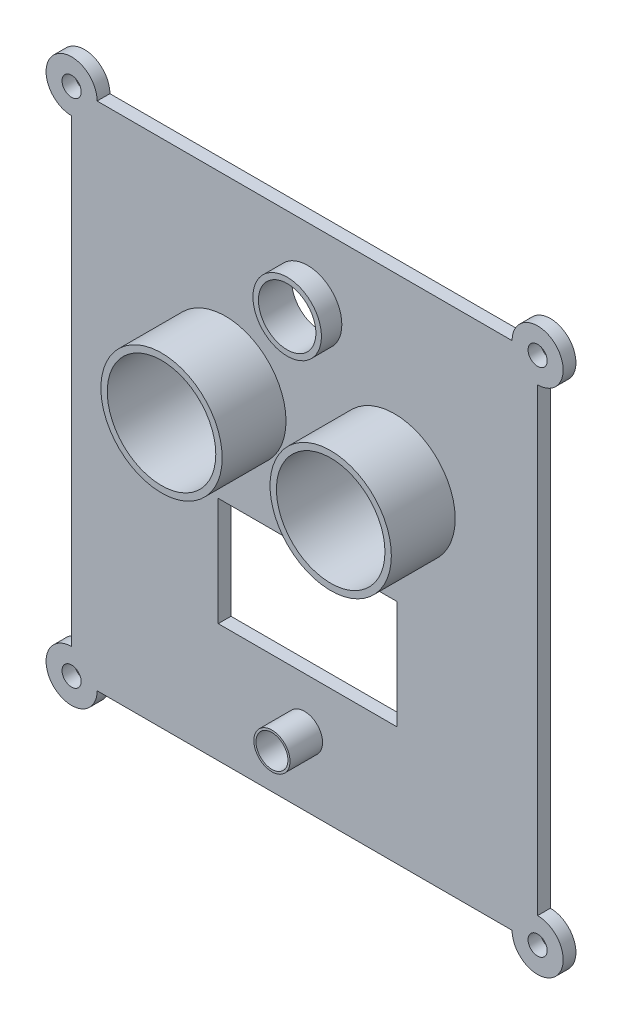
from build123d import *

# Parameters (mm, degrees)
SKETCH1_W           = 73
SKETCH1_H           = 80
SKETCH1_R           = 8.5
SKETCH1_R_2         = 4.5
SKETCH1_R_3         = 2.5
SKETCH1_W_2         = 28
SKETCH1_H_2         = 17
BOSS_EXTRUDE3_DEPTH = 2
SKETCH2_R           = 4
BOSS_EXTRUDE4_DEPTH = 2
SKETCH3_R           = 1.5
CUT_EXTRUDE1_DEPTH  = 10
SKETCH4_R           = 9.5
SKETCH4_R_2         = 8.5
BOSS_EXTRUDE5_DEPTH = 10
SKETCH5_R           = 5.360584101
SKETCH5_R_2         = 4.5
BOSS_EXTRUDE6_DEPTH = 5.2
SKETCH7_R           = 2.833966857
SKETCH7_R_2         = 2.5
BOSS_EXTRUDE7_DEPTH = 5.1


with BuildPart() as part:
    # Sketch1 → Boss-Extrude3 (new body)
    with BuildSketch(Plane.XY):
        with Locations((0, 10)):
            Rectangle(SKETCH1_W, SKETCH1_H)
        with Locations((-12.414904508, 21.373016215)):
            Circle(SKETCH1_R, mode=Mode.SUBTRACT)
        with Locations((14.085095492, 21.373016215)):
            Circle(SKETCH1_R, mode=Mode.SUBTRACT)
        with Locations((0.468085113, 38.834207529)):
            Circle(SKETCH1_R_2, mode=Mode.SUBTRACT)
        with Locations((-0.020060086, -19.374805823)):
            Circle(SKETCH1_R_3, mode=Mode.SUBTRACT)
        with Locations((0.468085113, -2.91182709)):
            Rectangle(SKETCH1_W_2, SKETCH1_H_2, mode=Mode.SUBTRACT)
    extrude(amount=BOSS_EXTRUDE3_DEPTH)

    # Sketch2 → Boss-Extrude4 (add)
    with BuildSketch(Plane.XY.offset(2)):
        with Locations((-36.5, 50)):
            Circle(SKETCH2_R)
        with Locations((36.5, 50)):
            Circle(SKETCH2_R)
        with Locations((36.5, -30)):
            Circle(SKETCH2_R)
        with Locations((-36.5, -30)):
            Circle(SKETCH2_R)
    extrude(amount=-BOSS_EXTRUDE4_DEPTH)

    # Sketch3 → Cut-Extrude1 (cut)
    with BuildSketch(Plane.XY.offset(2)):
        with Locations((-36.5, 50)):
            Circle(SKETCH3_R)
        with Locations((36.5, 50)):
            Circle(SKETCH3_R)
        with Locations((36.5, -30)):
            Circle(SKETCH3_R)
        with Locations((-36.5, -30)):
            Circle(SKETCH3_R)
    extrude(amount=-CUT_EXTRUDE1_DEPTH, mode=Mode.SUBTRACT)

    # Sketch4 → Boss-Extrude5 (add)
    with BuildSketch(Plane.XY.offset(2)):
        with Locations((-12.414904508, 21.373016215)):
            Circle(SKETCH4_R)
        with Locations((-12.414904508, 21.373016215)):
            Circle(SKETCH4_R_2, mode=Mode.SUBTRACT)
        with Locations((14.085095492, 21.373016215)):
            Circle(SKETCH4_R)
        with Locations((14.085095492, 21.373016215)):
            Circle(SKETCH4_R_2, mode=Mode.SUBTRACT)
    extrude(amount=BOSS_EXTRUDE5_DEPTH)

    # Sketch5 → Boss-Extrude6 (add)
    with BuildSketch(Plane(origin=(0, 0, 0), x_dir=(-1, 0, 0), z_dir=(0, 0, -1))):
        with Locations((-0.468085113, 38.834207529)):
            Circle(SKETCH5_R)
        with Locations((-0.468085113, 38.834207529)):
            Circle(SKETCH5_R_2, mode=Mode.SUBTRACT)
    extrude(amount=-BOSS_EXTRUDE6_DEPTH)

    # Sketch7 → Boss-Extrude7 (add)
    with BuildSketch(Plane.XY.offset(2)):
        with Locations((-0.020060086, -19.374805823)):
            Circle(SKETCH7_R)
        with Locations((-0.020060086, -19.374805823)):
            Circle(SKETCH7_R_2, mode=Mode.SUBTRACT)
    extrude(amount=BOSS_EXTRUDE7_DEPTH)


solid = part.part
